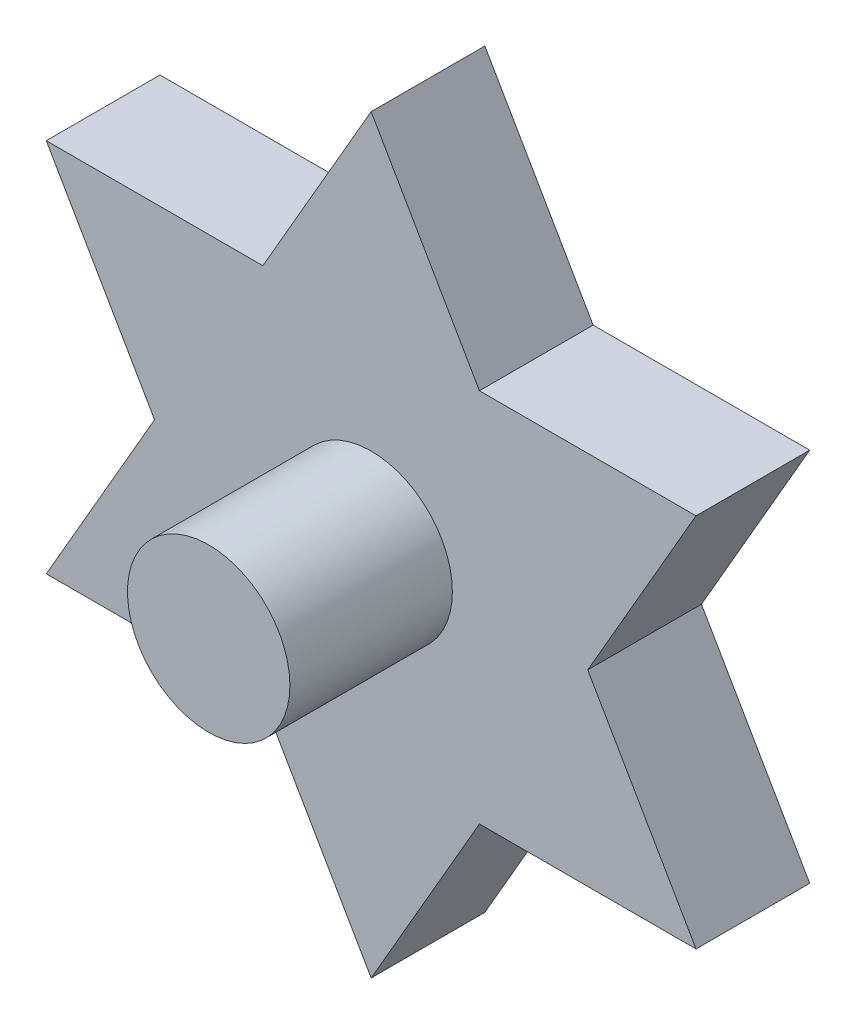
from build123d import *

# Parameters (mm, degrees)
BOSS_EXTRU_1_DEPTH = 7
ESQUISSE2_R        = 5
BOSS_EXTRU_2_DEPTH = 10


with BuildPart() as part:
    # Esquisse1 → Boss.-Extru.1 (new body)
    with BuildSketch(Plane.XY):
        Polygon((-20, 11.547005384), (-6.666666667, 11.547005384), (0, 23.094010768), (6.666666667, 11.547005384), (20, 11.547005384), (13.333333333, 0), (20, -11.547005384), (6.666666667, -11.547005384), (0, -23.094010768), (-6.666666667, -11.547005384), (-20, -11.547005384), (-13.333333333, 0), align=None)
    extrude(amount=BOSS_EXTRU_1_DEPTH)

    # Esquisse2 → Boss.-Extru.2 (add)
    with BuildSketch(Plane.XY.offset(7)):
        Circle(ESQUISSE2_R)
    extrude(amount=BOSS_EXTRU_2_DEPTH)


solid = part.part
